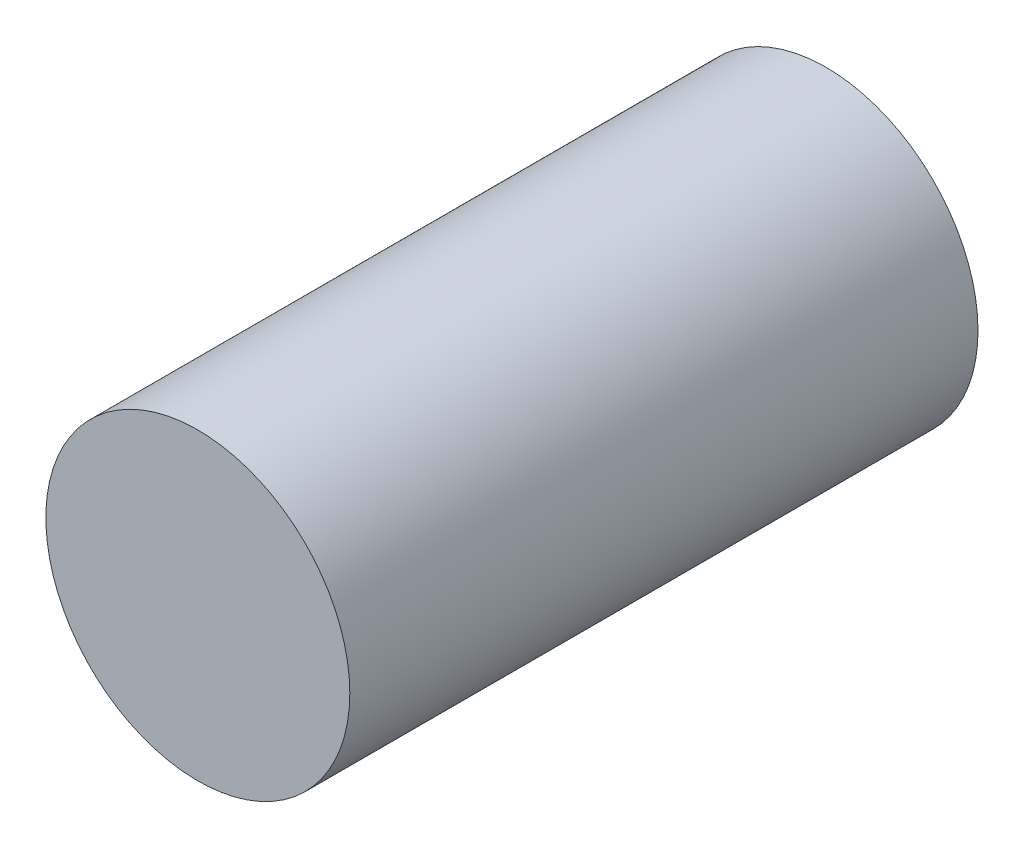
from build123d import *

# Parameters (mm, degrees)
SKETCH1_R           = 15
BOSS_EXTRUDE1_DEPTH = 31


with BuildPart() as part:
    # Sketch1 → Boss-Extrude1 (new body, symmetric)
    with BuildSketch(Plane.XY):
        Circle(SKETCH1_R)
    extrude(amount=BOSS_EXTRUDE1_DEPTH, both=True)


solid = part.part
